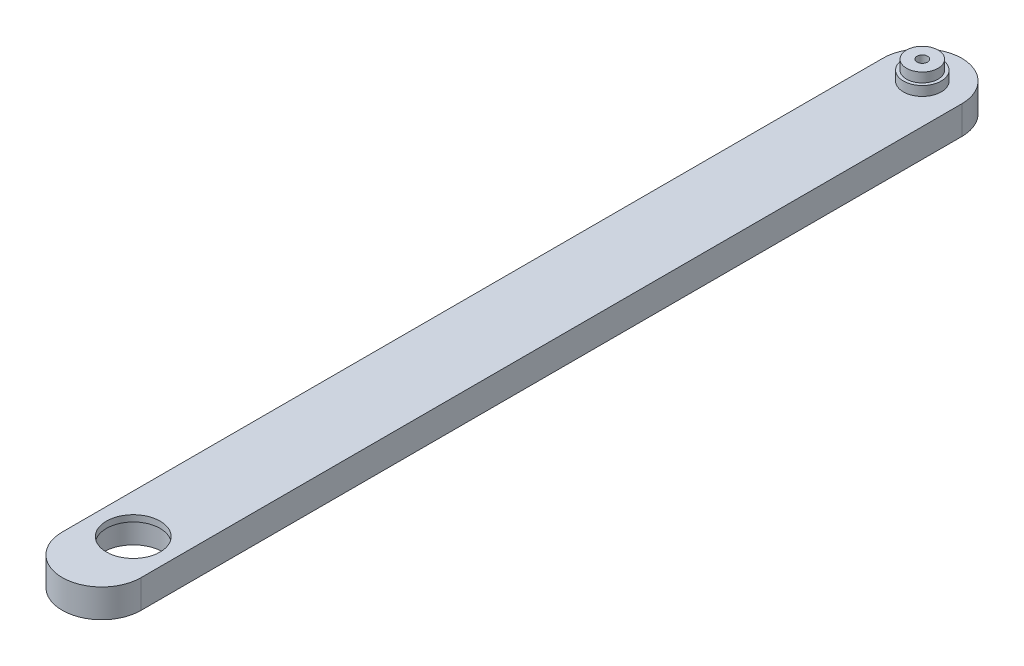
from build123d import *

# Parameters (mm, degrees)
EXTRUDE_1_DEPTH      = 10.5
EXTRUDE_1_DEPTH_BACK = 10.5
SKETCH_1_R           = 5
EXTRUDE_3_DEPTH      = 4.5
EXTRUDE_3_DEPTH_BACK = 4.5
SKETCH_7_R           = 6
EXTRUDE_4_DEPTH      = 3
EXTRUDE_START        = 3
SKETCH_8_R           = 6
EXTRUDE_5_DEPTH      = 3
SKETCH_9_R           = 9.5
CUT_EXTRUDE_1_DEPTH  = 7
SKETCH_10_R          = 8.5
CUT_EXTRUDE_2_DEPTH  = 274.096136919
HOLE_WIZARD_M4_1_D   = 3.3


with BuildPart() as part:
    # 스케치1 → 보스-돌출1 (new, two sides: drawn at the far end of the back side and taken through both)
    with BuildSketch(Plane(origin=(0, 0, 0), x_dir=(1, 0, 0), z_dir=(0, 1, 0)).offset(-EXTRUDE_1_DEPTH_BACK)):
        Circle(SKETCH_1_R)
    extrude(amount=EXTRUDE_1_DEPTH + EXTRUDE_1_DEPTH_BACK)

    # 스케치6 → 보스-돌출3 (add, two sides: drawn at the far end of the back side and taken through both)
    with BuildSketch(Plane(origin=(0, 0, 0), x_dir=(1, 0, 0), z_dir=(0, 1, 0)).offset(-EXTRUDE_3_DEPTH_BACK)):
        with BuildLine():
            Line((-12.5, 0), (-12.5, -260))
            ThreePointArc((-12.5, -260), (0, -272.5), (12.5, -260))
            Line((12.5, -260), (12.5, 0))
            ThreePointArc((12.5, 0), (0, 12.5), (-12.5, 0))
        make_face()
    extrude(amount=EXTRUDE_3_DEPTH + EXTRUDE_3_DEPTH_BACK)

    # 스케치7 → 보스-돌출4 (add)
    with BuildSketch(Plane.XZ.offset(4.5)):
        Circle(SKETCH_7_R)
    extrude(amount=EXTRUDE_4_DEPTH)

    # 스케치8 → 보스-돌출5 (add)
    with BuildSketch(Plane(origin=(0, 4.5, 0), x_dir=(1, 0, 0), z_dir=(0, 1, 0)).offset(EXTRUDE_START)):
        Circle(SKETCH_8_R)
    extrude(amount=-EXTRUDE_5_DEPTH)

    # 스케치9 → 컷-돌출1 (cut)
    with BuildSketch(Plane.XZ.offset(4.5)):
        with Locations((0, 250)):
            Circle(SKETCH_9_R)
    extrude(amount=-CUT_EXTRUDE_1_DEPTH, mode=Mode.SUBTRACT)

    # 스케치10 → 컷-돌출2 (cut, through all)
    with BuildSketch(Plane.XZ.offset(-2.5)):
        with Locations((0, 250)):
            Circle(SKETCH_10_R)
    extrude(amount=-CUT_EXTRUDE_2_DEPTH, mode=Mode.SUBTRACT)

    # M4 탭을 위한 탭 드릴1 (through all)
    with Locations(Plane(origin=(0, -10.5, 0), x_dir=(-1, 0, 0), z_dir=(0, -1, 0))):
        with Locations((0, 0)):
            Hole(HOLE_WIZARD_M4_1_D / 2)


solid = part.part
